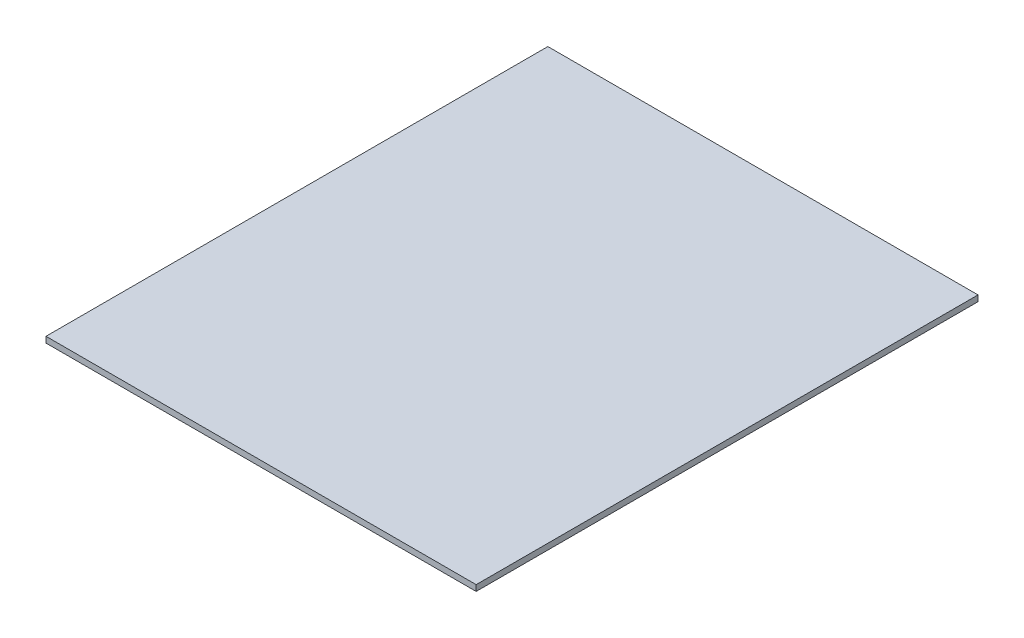
from build123d import *

# Parameters (mm, degrees)
SKETCH1_W           = 120
SKETCH1_H           = 140
BOSS_EXTRUDE1_DEPTH = 1.65


with BuildPart() as part:
    # Sketch1 → Boss-Extrude1 (new body)
    with BuildSketch(Plane(origin=(0, 0, 0), x_dir=(1, 0, 0), z_dir=(0, 1, 0))):
        Rectangle(SKETCH1_W, SKETCH1_H)
    extrude(amount=BOSS_EXTRUDE1_DEPTH)


solid = part.part
